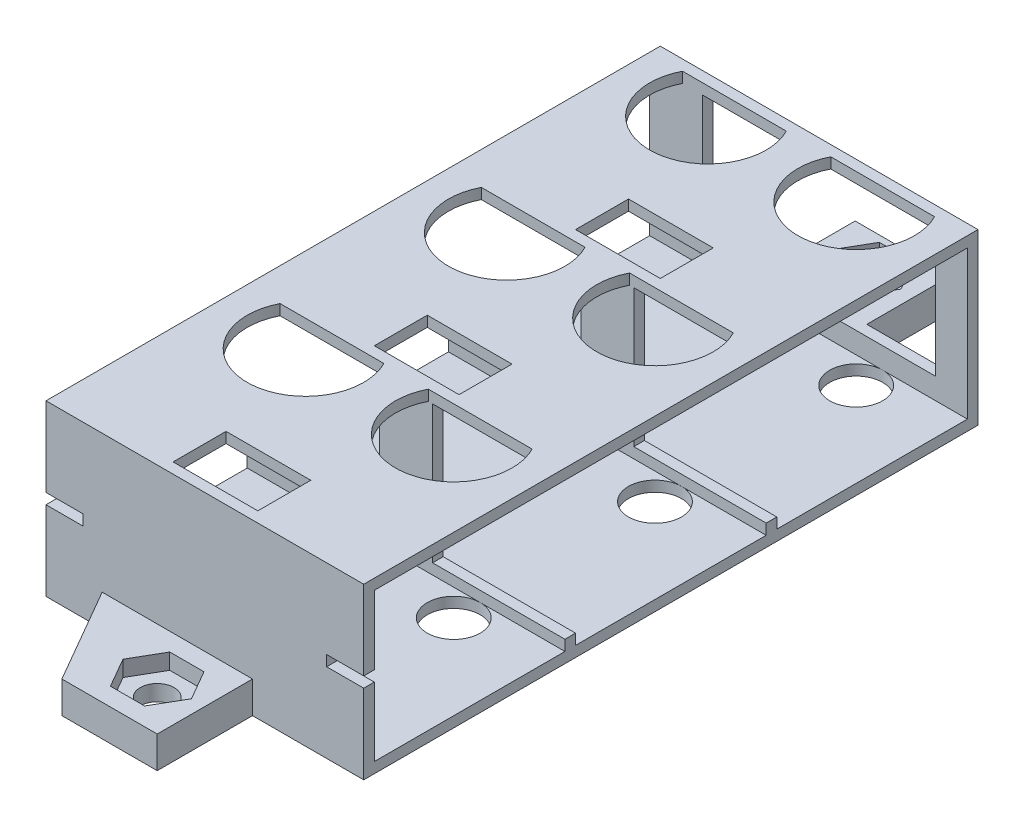
from build123d import *

# Parameters (mm, degrees)
SKETCH3_W           = 58
SKETCH3_H           = 16
BOSS_EXTRUDE2_DEPTH = 30
CUT_EXTRUDE2_REACH  = 3
SKETCH4_R           = 2.5
CUT_EXTRUDE6_REACH  = 3
SKETCH7_W           = 22
SKETCH7_H           = 12
BOSS_EXTRUDE4_REACH = 16
SKETCH9_W           = 5
SKETCH9_H           = 1
CHAMFER1_SIZE       = 5
SKETCH10_R          = 1.6
SKETCH10_W          = 9
SKETCH10_H          = 9
BOSS_EXTRUDE5_DEPTH = 3
CUT_EXTRUDE8_DEPTH  = 1.5
CUT_EXTRUDE9_REACH  = 69
SKETCH12_W          = 3.5
SKETCH12_H          = 1
CUT_EXTRUDE10_REACH = 18
SKETCH13_W          = 9
SKETCH13_H          = 1.1
CUT_EXTRUDE12_REACH = 18
SKETCH14_W          = 8
SKETCH14_H          = 5


with BuildPart() as part:
    # Sketch3 → Boss-Extrude2 (new body)
    with BuildSketch(Plane(origin=(0, 0, 0), x_dir=(0, 0, -1), z_dir=(1, 0, 0))):
        with Locations((29, 8)):
            Rectangle(SKETCH3_W, SKETCH3_H)
        Polygon((1, 1), (19, 1), (19, 2), (20, 2), (20, 1), (38, 1), (38, 2), (39, 2), (39, 1), (57, 1), (57, 15), (1, 15), align=None, mode=Mode.SUBTRACT)
    extrude(amount=BOSS_EXTRUDE2_DEPTH)

    # Sketch4 → Cut-Extrude2 (cut, up to next)
    with BuildSketch(Plane(origin=(0, 1, 0), x_dir=(1, 0, 0), z_dir=(0, 1, 0)), mode=Mode.PRIVATE) as cut_extrude2_sk1:
        with Locations(Location((22, 54.5, 0), (0, 0, 270))):  # turned: the seam where the file's is
            Circle(SKETCH4_R)
    cut_extrude2_tool1 = extrude(cut_extrude2_sk1.sketch, amount=-CUT_EXTRUDE2_REACH, mode=Mode.PRIVATE) & part.part
    add(cut_extrude2_tool1.solids().sort_by_distance((22, 1, -54.5))[0], mode=Mode.SUBTRACT)
    # Sketch4 → Cut-Extrude2 (cut, up to next)
    with BuildSketch(Plane(origin=(0, 1, 0), x_dir=(1, 0, 0), z_dir=(0, 1, 0)), mode=Mode.PRIVATE) as cut_extrude2_sk2:
        with Locations(Location((8, 54.5, 0), (0, 0, 270))):  # turned: the seam where the file's is
            Circle(SKETCH4_R)
    cut_extrude2_tool2 = extrude(cut_extrude2_sk2.sketch, amount=-CUT_EXTRUDE2_REACH, mode=Mode.PRIVATE) & part.part
    add(cut_extrude2_tool2.solids().sort_by_distance((8, 1, -54.5))[0], mode=Mode.SUBTRACT)
    # Sketch4 → Cut-Extrude2 (cut, up to next)
    with BuildSketch(Plane(origin=(0, 1, 0), x_dir=(1, 0, 0), z_dir=(0, 1, 0)), mode=Mode.PRIVATE) as cut_extrude2_sk3:
        with Locations(Location((8, 35.5, 0), (0, 0, 270))):  # turned: the seam where the file's is
            Circle(SKETCH4_R)
    cut_extrude2_tool3 = extrude(cut_extrude2_sk3.sketch, amount=-CUT_EXTRUDE2_REACH, mode=Mode.PRIVATE) & part.part
    add(cut_extrude2_tool3.solids().sort_by_distance((8, 1, -35.5))[0], mode=Mode.SUBTRACT)
    # Sketch4 → Cut-Extrude2 (cut, up to next)
    with BuildSketch(Plane(origin=(0, 1, 0), x_dir=(1, 0, 0), z_dir=(0, 1, 0)), mode=Mode.PRIVATE) as cut_extrude2_sk4:
        with Locations(Location((22, 35.5, 0), (0, 0, 270))):  # turned: the seam where the file's is
            Circle(SKETCH4_R)
    cut_extrude2_tool4 = extrude(cut_extrude2_sk4.sketch, amount=-CUT_EXTRUDE2_REACH, mode=Mode.PRIVATE) & part.part
    add(cut_extrude2_tool4.solids().sort_by_distance((22, 1, -35.5))[0], mode=Mode.SUBTRACT)
    # Sketch4 → Cut-Extrude2 (cut, up to next)
    with BuildSketch(Plane(origin=(0, 1, 0), x_dir=(1, 0, 0), z_dir=(0, 1, 0)), mode=Mode.PRIVATE) as cut_extrude2_sk5:
        with Locations(Location((8, 16.5, 0), (0, 0, 270))):  # turned: the seam where the file's is
            Circle(SKETCH4_R)
    cut_extrude2_tool5 = extrude(cut_extrude2_sk5.sketch, amount=-CUT_EXTRUDE2_REACH, mode=Mode.PRIVATE) & part.part
    add(cut_extrude2_tool5.solids().sort_by_distance((8, 1, -16.5))[0], mode=Mode.SUBTRACT)
    # Sketch4 → Cut-Extrude2 (cut, up to next)
    with BuildSketch(Plane(origin=(0, 1, 0), x_dir=(1, 0, 0), z_dir=(0, 1, 0)), mode=Mode.PRIVATE) as cut_extrude2_sk6:
        with Locations(Location((22, 16.5, 0), (0, 0, 270))):  # turned: the seam where the file's is
            Circle(SKETCH4_R)
    cut_extrude2_tool6 = extrude(cut_extrude2_sk6.sketch, amount=-CUT_EXTRUDE2_REACH, mode=Mode.PRIVATE) & part.part
    add(cut_extrude2_tool6.solids().sort_by_distance((22, 1, -16.5))[0], mode=Mode.SUBTRACT)

    # Sketch7 → Cut-Extrude6 (cut, up to next)
    with BuildSketch(Plane.XY.offset(-57), mode=Mode.PRIVATE) as cut_extrude6_sk1:
        with Locations((16, 9)):
            Rectangle(SKETCH7_W, SKETCH7_H)
    cut_extrude6_tool1 = extrude(cut_extrude6_sk1.sketch, amount=-CUT_EXTRUDE6_REACH, mode=Mode.PRIVATE) & part.part
    add(cut_extrude6_tool1.solids().sort_by_distance((16, 9, -57))[0], mode=Mode.SUBTRACT)

    # Sketch9 → Boss-Extrude4 (add, up to next)
    with BuildSketch(Plane(origin=(0, 2, 0), x_dir=(1, 0, 0), z_dir=(0, 1, 0)), mode=Mode.PRIVATE) as boss_extrude4_sk1:
        with Locations((15, 19.5)):
            Rectangle(SKETCH9_W, SKETCH9_H)
    boss_extrude4_tool1 = extrude(boss_extrude4_sk1.sketch, amount=BOSS_EXTRUDE4_REACH, mode=Mode.PRIVATE) - part.part
    add(boss_extrude4_tool1.solids().sort_by_distance((15, 2, -19.5))[0])
    # Sketch9 → Boss-Extrude4 (add, up to next)
    with BuildSketch(Plane(origin=(0, 2, 0), x_dir=(1, 0, 0), z_dir=(0, 1, 0)), mode=Mode.PRIVATE) as boss_extrude4_sk2:
        with Locations((15, 38.5)):
            Rectangle(SKETCH9_W, SKETCH9_H)
    boss_extrude4_tool2 = extrude(boss_extrude4_sk2.sketch, amount=BOSS_EXTRUDE4_REACH, mode=Mode.PRIVATE) - part.part
    add(boss_extrude4_tool2.solids().sort_by_distance((15, 2, -38.5))[0])

    # Chamfer1
    chamfer1_edges = [part.edges().sort_by_distance(p)[0] for p in [
        (12.5, 2, -19.5),
        (12.5, 2, -38.5),
    ]]
    chamfer(chamfer1_edges, length=CHAMFER1_SIZE)

    # Sketch10 → Boss-Extrude5 (add)
    with BuildSketch(Plane.XZ):
        Polygon((19.5, 0), (5.303847577, 0), (10.5, 9), (19.5, 9), align=None)
        with Locations(Location((15, 4.5, 0), (0, 0, 270))):  # turned: the seam where the file's is
            Circle(SKETCH10_R, mode=Mode.SUBTRACT)
        with Locations((15, -62.5)):
            Rectangle(SKETCH10_W, SKETCH10_H)
        with Locations(Location((15, -62.5, 0), (0, 0, 270))):  # turned: the seam where the file's is
            Circle(SKETCH10_R, mode=Mode.SUBTRACT)
    extrude(amount=-BOSS_EXTRUDE5_DEPTH)

    # Sketch11 → Cut-Extrude8 (cut)
    with BuildSketch(Plane(origin=(0, 3, 0), x_dir=(1, 0, 0), z_dir=(0, 1, 0))):
        Polygon((11.766838493, 62.5), (13.383419246, 59.7), (16.616580754, 59.7), (18.233161507, 62.5), (16.616580754, 65.3), (13.383419246, 65.3), align=None)
        Polygon((11.766838493, -4.5), (13.383419246, -7.3), (16.616580754, -7.3), (18.233161507, -4.5), (16.616580754, -1.7), (13.383419246, -1.7), align=None)
    extrude(amount=-CUT_EXTRUDE8_DEPTH, mode=Mode.SUBTRACT)

    # Sketch12 → Cut-Extrude9 (cut, up to next)
    with BuildSketch(Plane.XY, mode=Mode.PRIVATE) as cut_extrude9_sk1:
        with Locations((1.75, 8)):
            Rectangle(SKETCH12_W, SKETCH12_H)
    cut_extrude9_tool1 = extrude(cut_extrude9_sk1.sketch, amount=-CUT_EXTRUDE9_REACH, mode=Mode.PRIVATE) & part.part
    add(cut_extrude9_tool1.solids().sort_by_distance((1.75, 8, 0))[0], mode=Mode.SUBTRACT)
    # Sketch12 → Cut-Extrude9 (cut, up to next)
    with BuildSketch(Plane.XY, mode=Mode.PRIVATE) as cut_extrude9_sk2:
        with Locations((28.25, 8)):
            Rectangle(SKETCH12_W, SKETCH12_H)
    cut_extrude9_tool2 = extrude(cut_extrude9_sk2.sketch, amount=-CUT_EXTRUDE9_REACH, mode=Mode.PRIVATE) & part.part
    add(cut_extrude9_tool2.solids().sort_by_distance((28.25, 8, 0))[0], mode=Mode.SUBTRACT)

    # Sketch13 → Cut-Extrude10 (cut, up to next)
    with BuildSketch(Plane.XZ, mode=Mode.PRIVATE) as cut_extrude10_sk1:
        with Locations((15, -66.45)):
            Rectangle(SKETCH13_W, SKETCH13_H)
    cut_extrude10_tool1 = extrude(cut_extrude10_sk1.sketch, amount=-CUT_EXTRUDE10_REACH, mode=Mode.PRIVATE) & part.part
    add(cut_extrude10_tool1.solids().sort_by_distance((15, 0, -66.45))[0], mode=Mode.SUBTRACT)

    # Sketch14 → Cut-Extrude12 (cut, up to next)
    with BuildSketch(Plane(origin=(0, 16, 0), x_dir=(1, 0, 0), z_dir=(0, 1, 0)), mode=Mode.PRIVATE) as cut_extrude12_sk1:
        with BuildLine():
            Line((12.898979486, 57), (3.101020514, 57))
            ThreePointArc((3.101020514, 57), (8, 49), (12.898979486, 57))
        make_face()
    cut_extrude12_tool1 = extrude(cut_extrude12_sk1.sketch, amount=-CUT_EXTRUDE12_REACH, mode=Mode.PRIVATE) & part.part
    add(cut_extrude12_tool1.solids().sort_by_distance((8, 16, -53.441303))[0], mode=Mode.SUBTRACT)
    # Sketch14 → Cut-Extrude12 (cut, up to next)
    with BuildSketch(Plane(origin=(0, 16, 0), x_dir=(1, 0, 0), z_dir=(0, 1, 0)), mode=Mode.PRIVATE) as cut_extrude12_sk2:
        with BuildLine():
            Line((26.898979486, 57), (17.101020514, 57))
            ThreePointArc((17.101020514, 57), (22, 49), (26.898979486, 57))
        make_face()
    cut_extrude12_tool2 = extrude(cut_extrude12_sk2.sketch, amount=-CUT_EXTRUDE12_REACH, mode=Mode.PRIVATE) & part.part
    add(cut_extrude12_tool2.solids().sort_by_distance((22, 16, -53.441303))[0], mode=Mode.SUBTRACT)
    # Sketch14 → Cut-Extrude12 (cut, up to next)
    with BuildSketch(Plane(origin=(0, 16, 0), x_dir=(1, 0, 0), z_dir=(0, 1, 0)), mode=Mode.PRIVATE) as cut_extrude12_sk3:
        with BuildLine():
            Line((26.898979486, 38), (17.101020514, 38))
            ThreePointArc((17.101020514, 38), (22, 30), (26.898979486, 38))
        make_face()
    cut_extrude12_tool3 = extrude(cut_extrude12_sk3.sketch, amount=-CUT_EXTRUDE12_REACH, mode=Mode.PRIVATE) & part.part
    add(cut_extrude12_tool3.solids().sort_by_distance((22, 16, -34.441303))[0], mode=Mode.SUBTRACT)
    # Sketch14 → Cut-Extrude12 (cut, up to next)
    with BuildSketch(Plane(origin=(0, 16, 0), x_dir=(1, 0, 0), z_dir=(0, 1, 0)), mode=Mode.PRIVATE) as cut_extrude12_sk4:
        with BuildLine():
            Line((12.898979486, 38), (3.101020514, 38))
            ThreePointArc((3.101020514, 38), (8, 30), (12.898979486, 38))
        make_face()
    cut_extrude12_tool4 = extrude(cut_extrude12_sk4.sketch, amount=-CUT_EXTRUDE12_REACH, mode=Mode.PRIVATE) & part.part
    add(cut_extrude12_tool4.solids().sort_by_distance((8, 16, -34.441303))[0], mode=Mode.SUBTRACT)
    # Sketch14 → Cut-Extrude12 (cut, up to next)
    with BuildSketch(Plane(origin=(0, 16, 0), x_dir=(1, 0, 0), z_dir=(0, 1, 0)), mode=Mode.PRIVATE) as cut_extrude12_sk5:
        with BuildLine():
            Line((26.898979486, 19), (17.101020514, 19))
            ThreePointArc((17.101020514, 19), (22, 11), (26.898979486, 19))
        make_face()
    cut_extrude12_tool5 = extrude(cut_extrude12_sk5.sketch, amount=-CUT_EXTRUDE12_REACH, mode=Mode.PRIVATE) & part.part
    add(cut_extrude12_tool5.solids().sort_by_distance((22, 16, -15.441303))[0], mode=Mode.SUBTRACT)
    # Sketch14 → Cut-Extrude12 (cut, up to next)
    with BuildSketch(Plane(origin=(0, 16, 0), x_dir=(1, 0, 0), z_dir=(0, 1, 0)), mode=Mode.PRIVATE) as cut_extrude12_sk6:
        with BuildLine():
            Line((12.898979486, 19), (3.101020514, 19))
            ThreePointArc((3.101020514, 19), (8, 11), (12.898979486, 19))
        make_face()
    cut_extrude12_tool6 = extrude(cut_extrude12_sk6.sketch, amount=-CUT_EXTRUDE12_REACH, mode=Mode.PRIVATE) & part.part
    add(cut_extrude12_tool6.solids().sort_by_distance((8, 16, -15.441303))[0], mode=Mode.SUBTRACT)
    # Sketch14 → Cut-Extrude12 (cut, up to next)
    with BuildSketch(Plane(origin=(0, 16, 0), x_dir=(1, 0, 0), z_dir=(0, 1, 0)), mode=Mode.PRIVATE) as cut_extrude12_sk7:
        with Locations((15, 41.5)):
            Rectangle(SKETCH14_W, SKETCH14_H)
    cut_extrude12_tool7 = extrude(cut_extrude12_sk7.sketch, amount=-CUT_EXTRUDE12_REACH, mode=Mode.PRIVATE) & part.part
    add(cut_extrude12_tool7.solids().sort_by_distance((15, 16, -41.5))[0], mode=Mode.SUBTRACT)
    # Sketch14 → Cut-Extrude12 (cut, up to next)
    with BuildSketch(Plane(origin=(0, 16, 0), x_dir=(1, 0, 0), z_dir=(0, 1, 0)), mode=Mode.PRIVATE) as cut_extrude12_sk8:
        with Locations((15, 22.5)):
            Rectangle(SKETCH14_W, SKETCH14_H)
    cut_extrude12_tool8 = extrude(cut_extrude12_sk8.sketch, amount=-CUT_EXTRUDE12_REACH, mode=Mode.PRIVATE) & part.part
    add(cut_extrude12_tool8.solids().sort_by_distance((15, 16, -22.5))[0], mode=Mode.SUBTRACT)
    # Sketch14 → Cut-Extrude12 (cut, up to next)
    with BuildSketch(Plane(origin=(0, 16, 0), x_dir=(1, 0, 0), z_dir=(0, 1, 0)), mode=Mode.PRIVATE) as cut_extrude12_sk9:
        with Locations((15, 3.5)):
            Rectangle(SKETCH14_W, SKETCH14_H)
    cut_extrude12_tool9 = extrude(cut_extrude12_sk9.sketch, amount=-CUT_EXTRUDE12_REACH, mode=Mode.PRIVATE) & part.part
    add(cut_extrude12_tool9.solids().sort_by_distance((15, 16, -3.5))[0], mode=Mode.SUBTRACT)


solid = part.part
